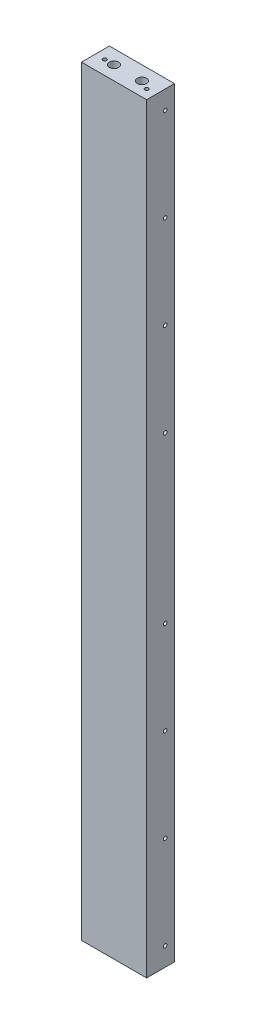
from build123d import *

# Parameters (mm, degrees)
SKETCH1_W                                  = 88.9
SKETCH1_H                                  = 38.1
BOSS_EXTRUDE1_DEPTH                        = 1038.225
SKETCH2_R                                  = 6.35
CUT_EXTRUDE1_DEPTH                         = 19.05
SKETCH3_R                                  = 6.35
CUT_EXTRUDE2_DEPTH                         = 19.05
F_10_0_1935_DIAMETER_HOLE1_D               = 4.9149
F_10_0_1935_DIAMETER_HOLE1_DEPTH           = 76.2
F_10_0_1935_DIAMETER_HOLE1_TIP             = 1.476584928
F_10_0_1935_DIAMETER_HOLE1_ON_FACE_2_D     = 4.9149
F_10_0_1935_DIAMETER_HOLE1_ON_FACE_2_DEPTH = 76.2
F_10_0_1935_DIAMETER_HOLE1_ON_FACE_2_TIP   = 1.476584928
F_10_0_1935_DIAMETER_HOLE2_D               = 4.9149
F_10_0_1935_DIAMETER_HOLE2_DEPTH           = 50.8
F_10_0_1935_DIAMETER_HOLE2_TIP             = 1.476584928


with BuildPart() as part:
    # Sketch1 → Boss-Extrude1 (new body)
    with BuildSketch(Plane(origin=(0, 0, 0), x_dir=(1, 0, 0), z_dir=(0, 1, 0))):
        with Locations((44.45, -19.05)):
            Rectangle(SKETCH1_W, SKETCH1_H)
    extrude(amount=BOSS_EXTRUDE1_DEPTH)

    # Sketch2 → Cut-Extrude1 (cut)
    with BuildSketch(Plane(origin=(0, 1038.225, 0), x_dir=(1, 0, 0), z_dir=(0, 1, 0))):
        with Locations((25.4, -19.05)):
            Circle(SKETCH2_R)
        with Locations((63.5, -19.05)):
            Circle(SKETCH2_R)
    extrude(amount=-CUT_EXTRUDE1_DEPTH, mode=Mode.SUBTRACT)

    # Sketch3 → Cut-Extrude2 (cut)
    with BuildSketch(Plane.XZ):
        with Locations((25.4, 19.05)):
            Circle(SKETCH3_R)
        with Locations((63.5, 19.05)):
            Circle(SKETCH3_R)
    extrude(amount=-CUT_EXTRUDE2_DEPTH, mode=Mode.SUBTRACT)

    # #10 (0.1935) Diameter Hole1
    with Locations(Plane(origin=(44.45, 0, 25.4), x_dir=(0, 0, -1), z_dir=(0, -1, 0))):
        with Locations((0, 0)):
            Hole(F_10_0_1935_DIAMETER_HOLE1_D / 2, depth=F_10_0_1935_DIAMETER_HOLE1_DEPTH)
            with Locations((0, 0, -(F_10_0_1935_DIAMETER_HOLE1_DEPTH + F_10_0_1935_DIAMETER_HOLE1_TIP / 2))):  # 118° drill point
                Cone(0, F_10_0_1935_DIAMETER_HOLE1_D / 2, F_10_0_1935_DIAMETER_HOLE1_TIP, mode=Mode.SUBTRACT)

    # #10 (0.1935) Diameter Hole1 on face 2
    with Locations(Plane(origin=(12.7, 1038.225, 19.05), x_dir=(0, 0, 1), z_dir=(0, 1, 0))):
        with Locations((0, 0), (6.35, 63.5)):
            Hole(F_10_0_1935_DIAMETER_HOLE1_ON_FACE_2_D / 2, depth=F_10_0_1935_DIAMETER_HOLE1_ON_FACE_2_DEPTH)
            with Locations((0, 0, -(F_10_0_1935_DIAMETER_HOLE1_ON_FACE_2_DEPTH + F_10_0_1935_DIAMETER_HOLE1_ON_FACE_2_TIP / 2))):  # 118° drill point
                Cone(0, F_10_0_1935_DIAMETER_HOLE1_ON_FACE_2_D / 2, F_10_0_1935_DIAMETER_HOLE1_ON_FACE_2_TIP, mode=Mode.SUBTRACT)

    # #10 (0.1935) Diameter Hole2
    with Locations(Plane(origin=(88.9, 25.4, 12.7), x_dir=(0, 0, 1), z_dir=(1, 0, 0))):
        with Locations((0, 0), (0, -127), (0, -254), (0, -381), (0, -606.425), (0, -733.425), (0, -860.425), (0, -987.425)):
            Hole(F_10_0_1935_DIAMETER_HOLE2_D / 2, depth=F_10_0_1935_DIAMETER_HOLE2_DEPTH)
            with Locations((0, 0, -(F_10_0_1935_DIAMETER_HOLE2_DEPTH + F_10_0_1935_DIAMETER_HOLE2_TIP / 2))):  # 118° drill point
                Cone(0, F_10_0_1935_DIAMETER_HOLE2_D / 2, F_10_0_1935_DIAMETER_HOLE2_TIP, mode=Mode.SUBTRACT)


solid = part.part
